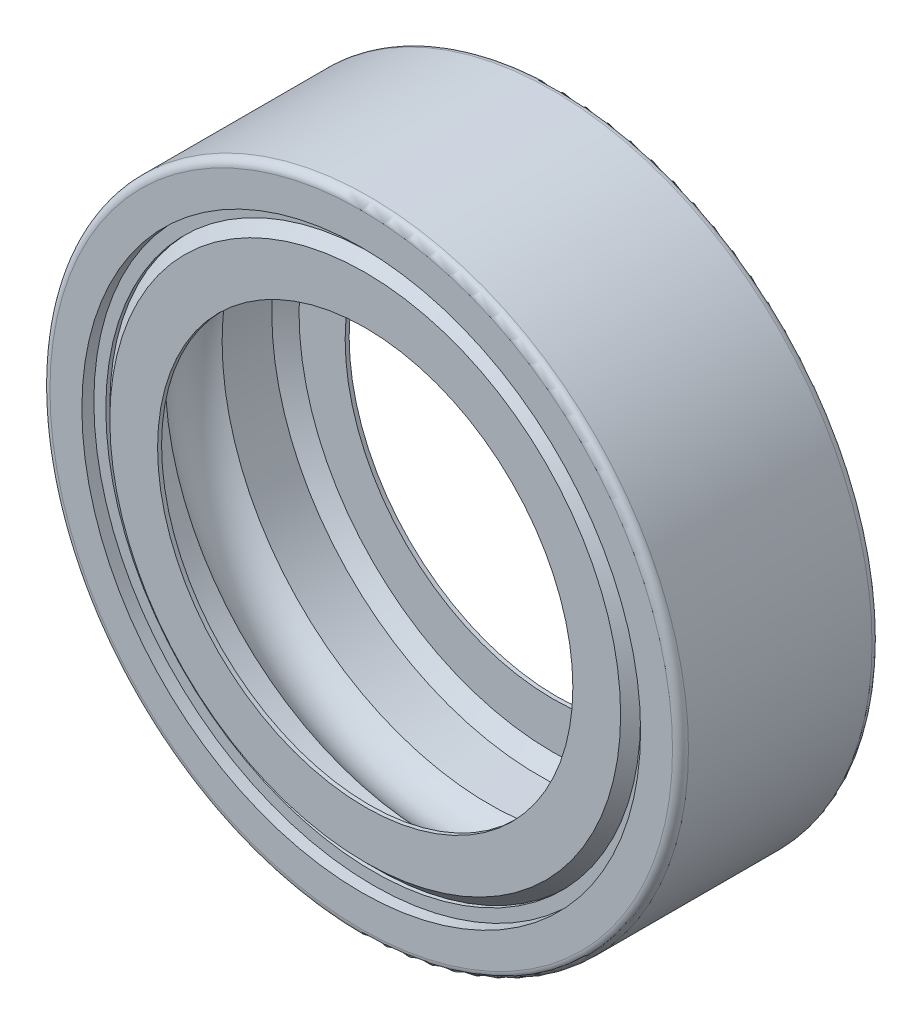
from build123d import *


with BuildPart() as part:
    # Sketch1 → Revolve1 (revolve)
    with BuildSketch(Plane(origin=(0, 0, 0), x_dir=(0, 0, -1), z_dir=(1, 0, 0))):
        with BuildLine():
            Line((-2.5, 7), (-2.5, 7.8))
            ThreePointArc((-2.5, 7.8), (-2.441421356, 7.941421356), (-2.3, 8))
            Line((-2.3, 8), (2.3, 8))
            ThreePointArc((2.3, 8), (2.441421356, 7.941421356), (2.5, 7.8))
            Line((2.5, 7.8), (2.5, 7))
            Line((2.5, 7), (2.2, 7))
            Line((2.2, 7), (2.2, 6.7))
            Line((2.2, 6.7), (2.1, 6.7))
            Line((2.1, 6.7), (2.4, 6.4))
            Line((2.4, 6.4), (2.4, 5.202907901))
            Line((2.4, 5.202907901), (2.3, 5.202907901))
            Line((2.3, 5.202907901), (2.3, 6.358578644))
            Line((2.3, 6.358578644), (1.958578644, 6.7))
            Line((1.958578644, 6.7), (0.714142843, 6.7))
            ThreePointArc((0.714142843, 6.7), (0, 7), (-0.714142843, 6.7))
            Line((-0.714142843, 6.7), (-1.958578644, 6.7))
            Line((-1.958578644, 6.7), (-2.3, 6.358578644))
            Line((-2.3, 6.358578644), (-2.3, 5.202907901))
            Line((-2.3, 5.202907901), (-2.4, 5.202907901))
            Line((-2.4, 5.202907901), (-2.4, 6.4))
            Line((-2.4, 6.4), (-2.1, 6.7))
            Line((-2.1, 6.7), (-2.2, 6.7))
            Line((-2.2, 6.7), (-2.2, 7))
            Line((-2.2, 7), (-2.5, 7))
        make_face()
    revolve(axis=Axis((0, 0, 6.755399071), (0, 0, -1)))


solid = part.part
